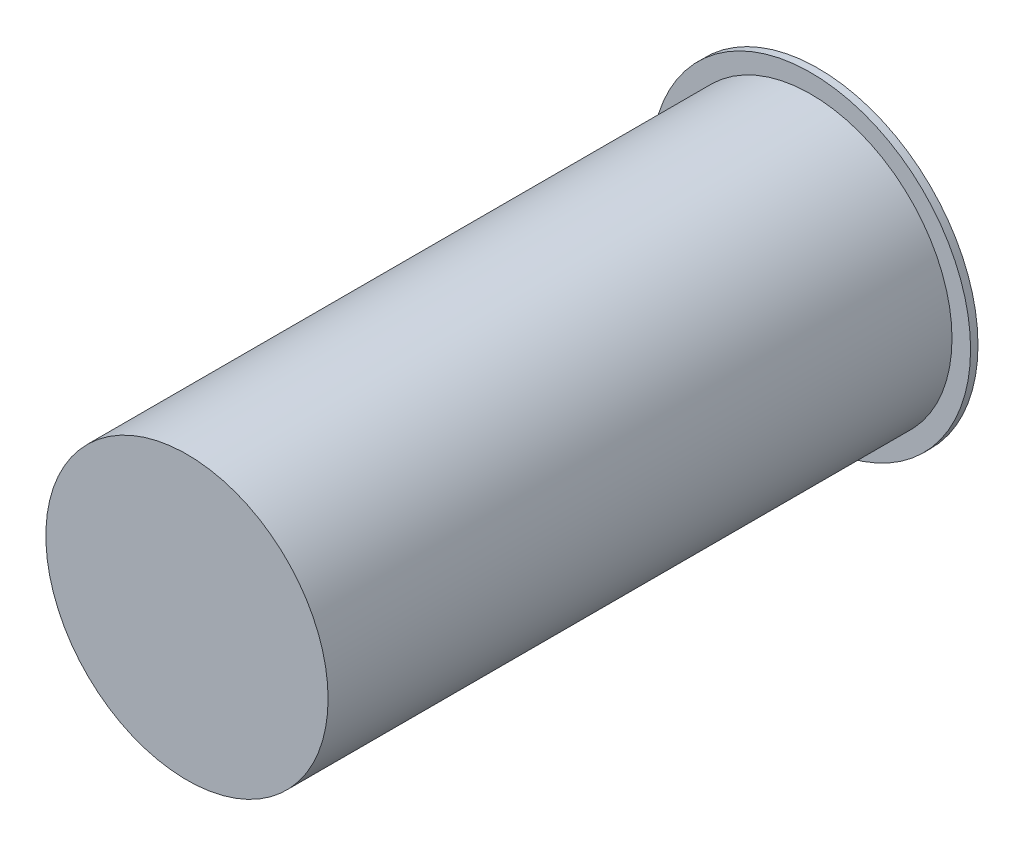
from build123d import *


with BuildPart() as part:
    # Sketch1 → Revolve1 (revolve)
    with BuildSketch(Plane(origin=(0, 0, 0), x_dir=(1, 0, 0), z_dir=(0, 1, 0))):
        Polygon((0, 2), (0, -42), (9.5, -42), (9.5, 0), (10.75, 0), (10.75, 0.5), (8, 2), align=None)
    revolve(axis=Axis((0, 0, 0), (0, 0, -1)))


solid = part.part
